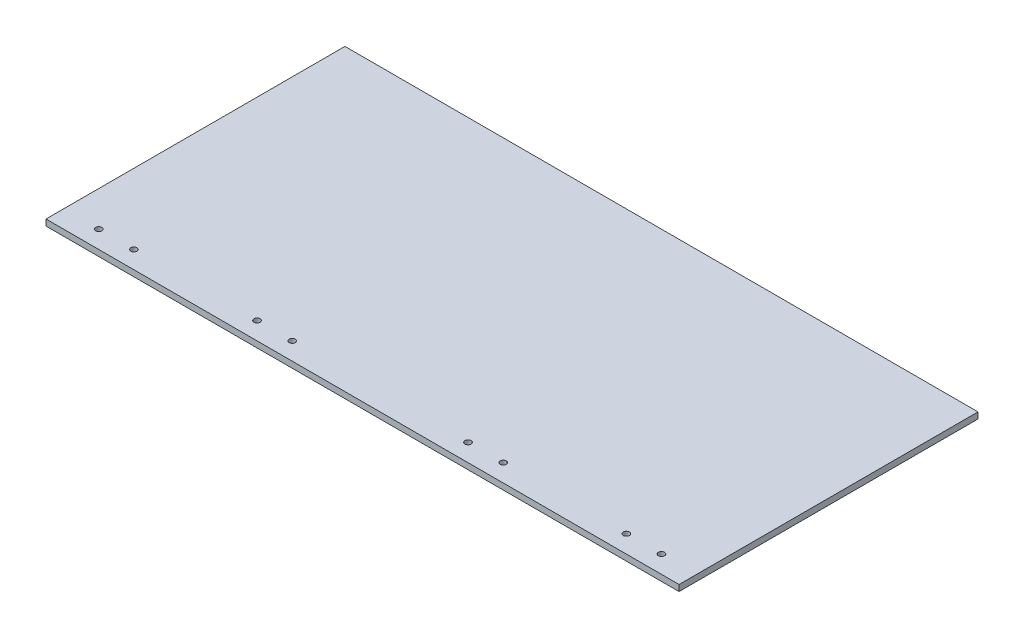
from build123d import *

# Parameters (mm, degrees)
SKETCH1_W           = 360
SKETCH1_H           = 170
BOSS_EXTRUDE1_DEPTH = 3.5
SKETCH2_R           = 1.75
CUT_EXTRUDE1_DEPTH  = 3.5


with BuildPart() as part:
    # Sketch1 → Boss-Extrude1 (new body)
    with BuildSketch(Plane(origin=(0, 0, 0), x_dir=(1, 0, 0), z_dir=(0, 1, 0))):
        with Locations((180, 85)):
            Rectangle(SKETCH1_W, SKETCH1_H)
    extrude(amount=BOSS_EXTRUDE1_DEPTH)

    # Sketch2 → Cut-Extrude1 (cut)
    with BuildSketch(Plane(origin=(0, 3.5, 0), x_dir=(1, 0, 0), z_dir=(0, 1, 0))):
        with Locations((20, 10)):
            Circle(SKETCH2_R)
        with Locations((40, 10)):
            Circle(SKETCH2_R)
        with Locations((110, 10)):
            Circle(SKETCH2_R)
        with Locations((130, 10)):
            Circle(SKETCH2_R)
        with Locations((230, 10)):
            Circle(SKETCH2_R)
        with Locations((250, 10)):
            Circle(SKETCH2_R)
        with Locations((320, 10)):
            Circle(SKETCH2_R)
        with Locations((340, 10)):
            Circle(SKETCH2_R)
    extrude(amount=-CUT_EXTRUDE1_DEPTH, mode=Mode.SUBTRACT)


solid = part.part
